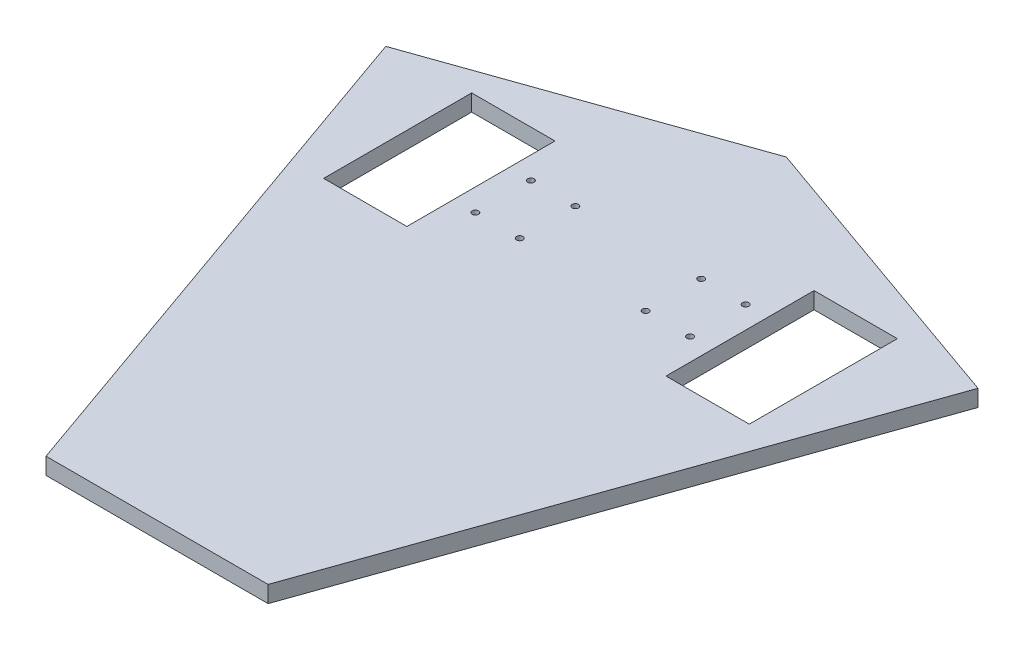
from build123d import *

# Parameters (mm, degrees)
BOSS_EXTRU_1_DEPTH        = 9
ESQUISSE2_W               = 45
ESQUISSE2_H               = 80
ENL_V_MAT_EXTRU_2_DEPTH   = 9
D_GAGEMENT_M31_AT_2_COUNT = 2
D_GAGEMENT_M31_AT_2_PITCH = 24


with BuildPart() as part:
    # Esquisse1 → Boss.-Extru.1 (new body)
    with BuildSketch(Plane(origin=(0, 0, 0), x_dir=(1, 0, 0), z_dir=(0, 1, 0))):
        Polygon((0, 110), (-160, 53.578166916), (-60, -230), (60, -230), (160, 53.578166916), align=None)
    extrude(amount=-BOSS_EXTRU_1_DEPTH)

    # Esquisse2 → Enlèv. mat.-Extru.2 (cut)
    with BuildSketch(Plane(origin=(0, 0, 0), x_dir=(1, 0, 0), z_dir=(0, 1, 0))):
        with Locations((-92.5, 15)):
            Rectangle(ESQUISSE2_W, ESQUISSE2_H)
    enl_v_mat_extru_2 = extrude(amount=-ENL_V_MAT_EXTRU_2_DEPTH, mode=Mode.SUBTRACT)

    # Symétrie1: Enlèv. mat.-Extru.2 across plane
    add(enl_v_mat_extru_2.mirror(Plane(origin=(0, 0, 0), x_dir=(0, 0, 1), z_dir=(1, 0, 0))), mode=Mode.SUBTRACT)

    # Esquisse4 → Dégagement M31 (revolve, cut)
    with BuildSketch(Plane(origin=(-58, 0, 0), x_dir=(0, 0, 1), z_dir=(1, 0, 0))):
        Polygon((0, 0), (0, 11.021463052), (1.7, 10), (1.7, 0), align=None)
    d_gagement_m31 = revolve(axis=Axis((-58, 6.35, 0), (0, -1, 0)), mode=Mode.SUBTRACT)

    # Dégagement M31 at 2: Dégagement M31 ×2
    with Locations(*[(i * D_GAGEMENT_M31_AT_2_PITCH, 0, 0) for i in range(1, D_GAGEMENT_M31_AT_2_COUNT)]):
        add(d_gagement_m31, mode=Mode.SUBTRACT)

    # Symétrie2: Dégagement M31 across plane
    add(d_gagement_m31.mirror(Plane.XY.offset(-15)), mode=Mode.SUBTRACT)

    # Symétrie2 copy 1 sketch → Symétrie2 copy 1 (revolve, cut)
    with BuildSketch(Plane(origin=(-34, 0, -30), x_dir=(0, 0, -1), z_dir=(1, 0, 0))):
        Polygon((0, 0), (0, -11.021463052), (1.7, -10), (1.7, 0), align=None)
    revolve(axis=Axis((-34, 6.35, -30), (0, 1, 0)), mode=Mode.SUBTRACT)

    # Symétrie3: Dégagement M31 across plane
    add(d_gagement_m31.mirror(Plane(origin=(0, 0, 0), x_dir=(0, 0, 1), z_dir=(1, 0, 0))), mode=Mode.SUBTRACT)

    # Symétrie3 copy 1 sketch → Symétrie3 copy 1 (revolve, cut)
    with BuildSketch(Plane(origin=(58, 0, -30), x_dir=(0, 0, -1), z_dir=(-1, 0, 0))):
        Polygon((0, 0), (0, 11.021463052), (1.7, 10), (1.7, 0), align=None)
    revolve(axis=Axis((58, 6.35, -30), (0, -1, 0)), mode=Mode.SUBTRACT)

    # Symétrie3 copy 2 sketch → Symétrie3 copy 2 (revolve, cut)
    with BuildSketch(Plane(origin=(34, 0, -30), x_dir=(0, 0, -1), z_dir=(-1, 0, 0))):
        Polygon((0, 0), (0, 11.021463052), (1.7, 10), (1.7, 0), align=None)
    revolve(axis=Axis((34, 6.35, -30), (0, -1, 0)), mode=Mode.SUBTRACT)

    # Symétrie3 copy 3 sketch → Symétrie3 copy 3 (revolve, cut)
    with BuildSketch(Plane.ZY.offset(-34)):
        Polygon((0, 0), (0, -11.021463052), (1.7, -10), (1.7, 0), align=None)
    revolve(axis=Axis((34, 6.35, 0), (0, 1, 0)), mode=Mode.SUBTRACT)


solid = part.part
